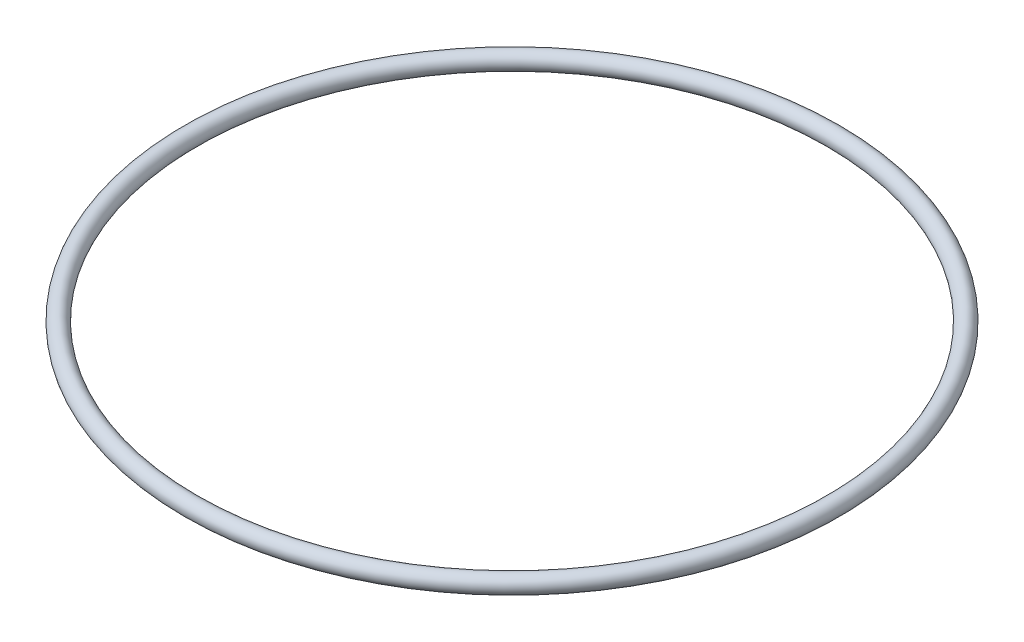
from build123d import *

# Parameters (mm, degrees)
SKETCH1_R = 0.79375


with BuildPart() as part:
    # Sketch1 → Revolve2 (revolve)
    with BuildSketch(Plane.XY):
        with Locations((29.36875, 0)):
            Circle(SKETCH1_R)
    revolve(axis=Axis((0, 6.667415751, 0), (0, -1, 0)))


solid = part.part
